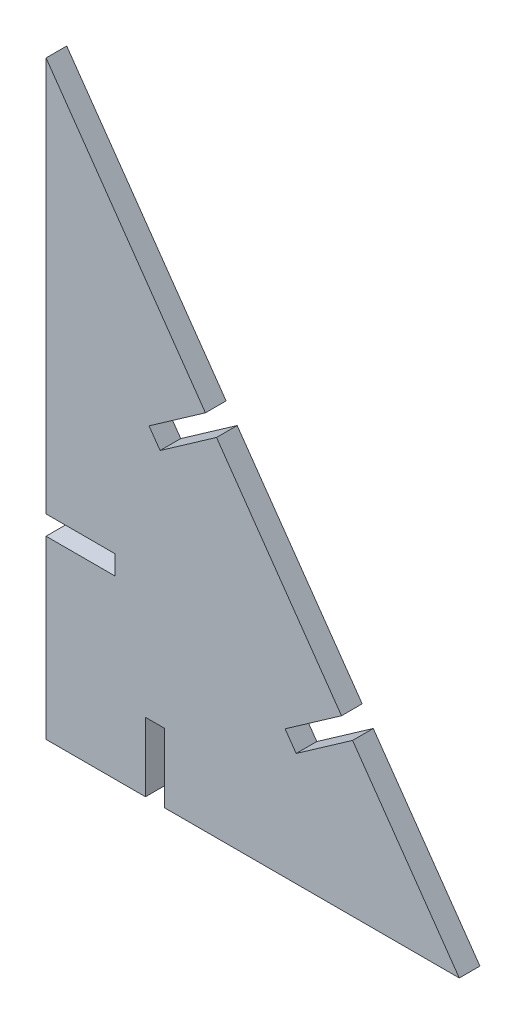
from build123d import *

# Parameters (mm, degrees)
BOSS_EXTRU_1_DEPTH = 3


with BuildPart() as part:
    # Esquisse1 → Boss.-Extru.1 (new body)
    with BuildSketch(Plane.XY):
        Polygon((0, 0), (14.434548486, 0), (14.434548486, 10), (17.234548486, 10), (17.234548486, 0), (60, 0), (44.50571222, 22.128136209), (36.314191777, 16.392371846), (34.708177755, 18.68599757), (42.899698198, 24.421761933), (24.749576179, 50.342822517), (16.558055736, 44.607058153), (14.952041714, 46.900683877), (23.143562157, 52.636448241), (0, 85.688880405), (0, 28.353429751), (10, 28.353429751), (10, 25.553429751), (0, 25.553429751), align=None)
    extrude(amount=BOSS_EXTRU_1_DEPTH)


solid = part.part
